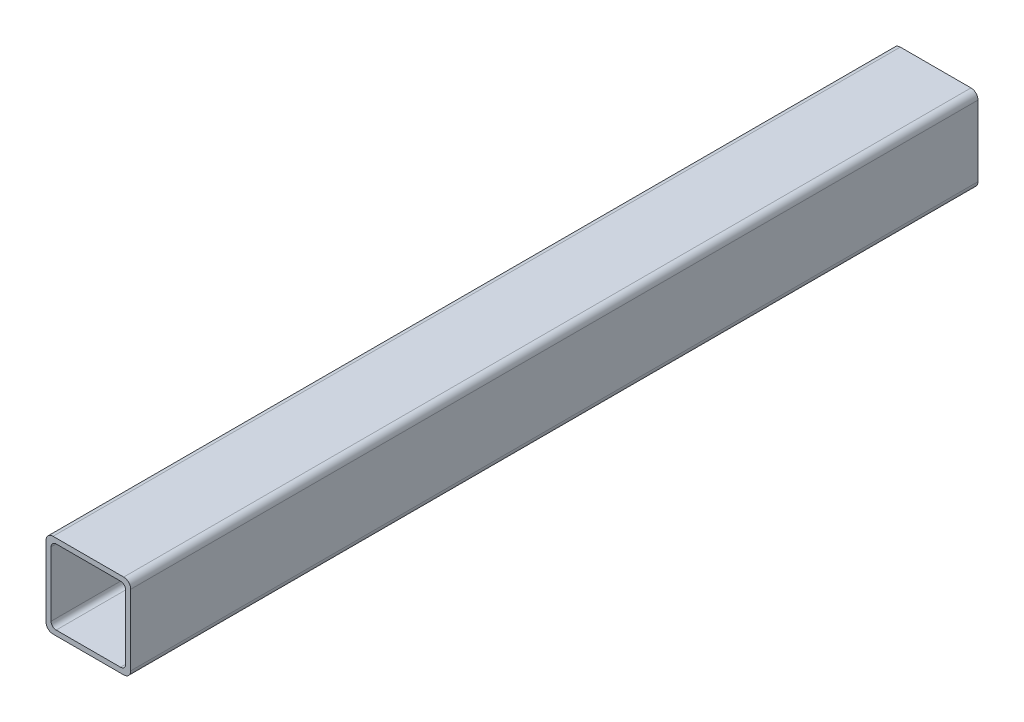
from build123d import *

# Parameters (mm, degrees)
BOSS_EXTRUDE1_DEPTH = 254


with BuildPart() as part:
    # Sketch1 → Boss-Extrude1 (new body)
    with BuildSketch(Plane(origin=(0, 0, -3683), x_dir=(-1, 0, 0), z_dir=(0, 0, -1))):
        with BuildLine():
            Line((12.7, -10.5918), (12.7, 10.5918))
            ThreePointArc((12.7, 10.5918), (12.082522516, 12.082522516), (10.5918, 12.7))
            Line((10.5918, 12.7), (-10.5918, 12.7))
            ThreePointArc((-10.5918, 12.7), (-12.082522516, 12.082522516), (-12.7, 10.5918))
            Line((-12.7, 10.5918), (-12.7, -10.5918))
            ThreePointArc((-12.7, -10.5918), (-12.082522516, -12.082522516), (-10.5918, -12.7))
            Line((-10.5918, -12.7), (10.5918, -12.7))
            ThreePointArc((10.5918, -12.7), (12.082522516, -12.082522516), (12.7, -10.5918))
        make_face()
        with BuildLine():
            Line((11.176, 9.652), (11.176, -9.652))
            ThreePointArc((11.176, -9.652), (10.729630735, -10.729630735), (9.652, -11.176))
            Line((9.652, -11.176), (-9.652, -11.176))
            ThreePointArc((-9.652, -11.176), (-10.729630735, -10.729630735), (-11.176, -9.652))
            Line((-11.176, -9.652), (-11.176, 9.652))
            ThreePointArc((-11.176, 9.652), (-10.729630735, 10.729630735), (-9.652, 11.176))
            Line((-9.652, 11.176), (9.652, 11.176))
            ThreePointArc((9.652, 11.176), (10.729630735, 10.729630735), (11.176, 9.652))
        make_face(mode=Mode.SUBTRACT)
    extrude(amount=-BOSS_EXTRUDE1_DEPTH)


solid = part.part
